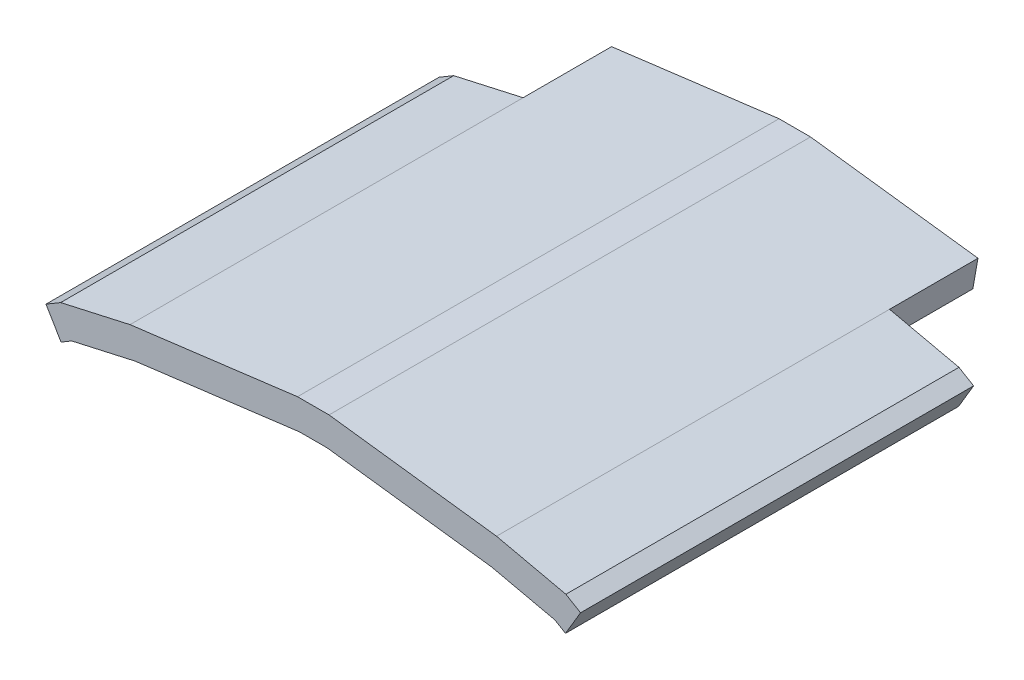
from build123d import *

# Parameters (mm, degrees)
BOSS_EXTRUDE1_DEPTH = 50.8
BOSS_EXTRUDE2_DEPTH = 11.43


with BuildPart() as part:
    # Sketch1 → Boss-Extrude1 (new body)
    with BuildSketch(Plane.XY):
        Polygon((-2.037826091, 0), (2.037826091, 0), (4.901371199, -0.364452471), (9.560729749, -0.957463816), (23.681538514, -2.754663947), (32.64962373, -4.768284593), (34.544, -5.892440119), (32.599653531, -9.168965231), (31.225129901, -8.353299221), (23.022216919, -6.511484102), (9.079699287, -4.736975649), (4.420340738, -4.143964304), (1.796344675, -3.81), (-1.796344675, -3.81), (-4.420340738, -4.143964304), (-9.079699287, -4.736975649), (-23.022216919, -6.511484102), (-31.225129901, -8.353299221), (-32.599653531, -9.168965231), (-34.544, -5.892440119), (-32.64962373, -4.768284593), (-23.681538514, -2.754663947), (-9.560729749, -0.957463816), (-4.901371199, -0.364452471), align=None)
    extrude(amount=BOSS_EXTRUDE1_DEPTH)

    # Sketch2 → Boss-Extrude2 (add)
    with BuildSketch(Plane(origin=(0, 0, 0), x_dir=(-1, 0, 0), z_dir=(0, 0, -1))):
        Polygon((23.022216919, -6.511484102), (1.796344675, -3.81), (-1.796344675, -3.81), (-23.022216919, -6.511484102), (-23.681538514, -2.754663947), (-2.037826091, 0), (2.037826091, 0), (23.681538514, -2.754663947), align=None)
    extrude(amount=BOSS_EXTRUDE2_DEPTH)


solid = part.part
